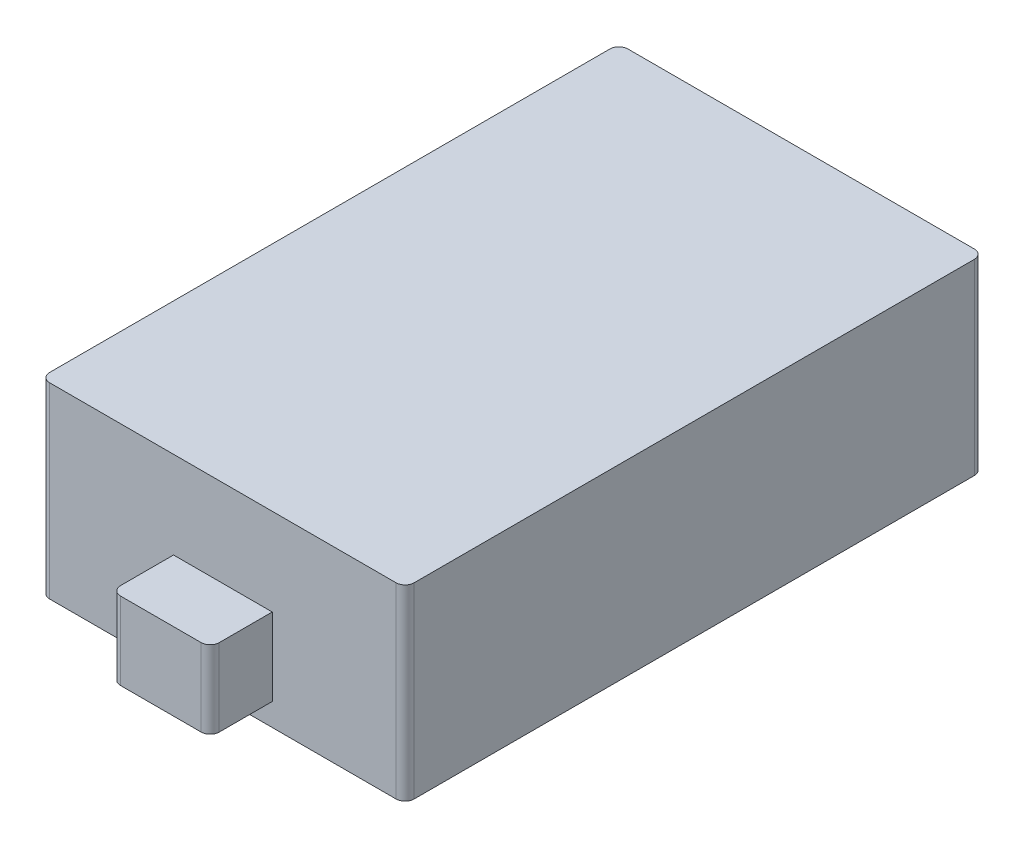
from build123d import *

# Parameters (mm, degrees)
SKETCH1_W           = 32.3
SKETCH1_H           = 51.25
BOSS_EXTRUDE2_DEPTH = 16.6
SKETCH2_W           = 8.75
SKETCH2_H           = 6.87
BOSS_EXTRUDE3_DEPTH = 5.5
SKETCH3_W           = 8.75
SKETCH3_H           = 6.929487278
BOSS_EXTRUDE4_DEPTH = 5.5
FILLET1_R           = 0.8


with BuildPart() as part:
    # Sketch1 → Boss-Extrude2 (new body)
    with BuildSketch(Plane(origin=(0, 0, 0), x_dir=(1, 0, 0), z_dir=(0, 1, 0))):
        Rectangle(SKETCH1_W, SKETCH1_H)
    extrude(amount=BOSS_EXTRUDE2_DEPTH)

    # Sketch2 → Boss-Extrude3 (add)
    with BuildSketch(Plane.XY.offset(25.625)):
        with Locations((0, 5.435)):
            Rectangle(SKETCH2_W, SKETCH2_H)
    extrude(amount=BOSS_EXTRUDE3_DEPTH)

    # Sketch3 → Boss-Extrude4 (add)
    with BuildSketch(Plane(origin=(0, 0, -25.625), x_dir=(-1, 0, 0), z_dir=(0, 0, -1))):
        with Locations((0, 5.464743639)):
            Rectangle(SKETCH3_W, SKETCH3_H)
    extrude(amount=BOSS_EXTRUDE4_DEPTH)

    # Fillet1
    fillet1_edges = [part.edges().sort_by_distance(p)[0] for p in [
        (-4.375, 5.435, 31.125),
        (4.375, 5.435, 31.125),
        (4.375, 5.464743639, -31.125),
        (-4.375, 5.464743639, -31.125),
        (-16.15, 8.3, -25.625),
        (16.15, 8.3, -25.625),
        (16.15, 8.3, 25.625),
        (-16.15, 8.3, 25.625),
    ]]
    fillet(fillet1_edges, radius=FILLET1_R)


solid = part.part
